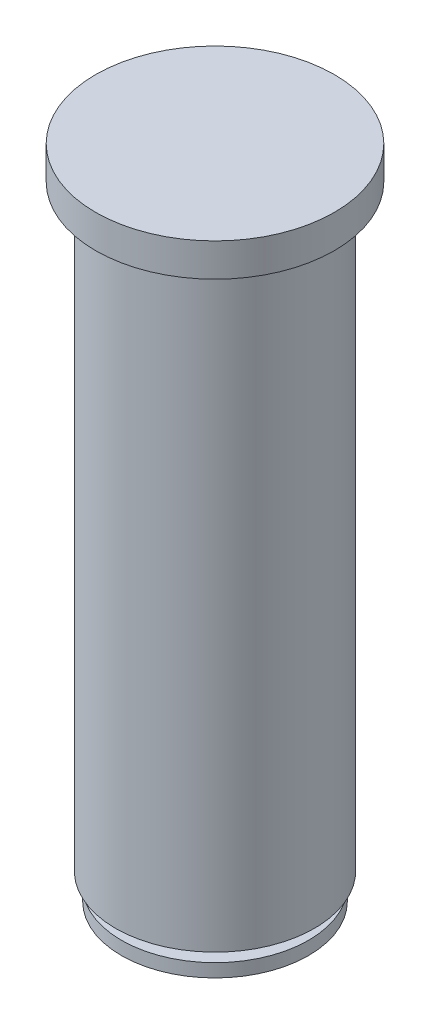
from build123d import *

# Parameters (mm, degrees)
SKETCH1_R           = 15
BOSS_EXTRUDE1_DEPTH = 90
SKETCH2_R           = 18
BOSS_EXTRUDE2_DEPTH = 5
SKETCH3_R           = 2.5
BOSS_EXTRUDE3_DEPTH = 2
SKETCH4_R           = 14.11079173
BOSS_EXTRUDE4_DEPTH = 2


with BuildPart() as part:
    # Sketch1 → Boss-Extrude1 (new body)
    with BuildSketch(Plane(origin=(0, 0, 0), x_dir=(1, 0, 0), z_dir=(0, 1, 0))):
        Circle(SKETCH1_R)
    extrude(amount=BOSS_EXTRUDE1_DEPTH)

    # Sketch2 → Boss-Extrude2 (add)
    with BuildSketch(Plane(origin=(0, 90, 0), x_dir=(1, 0, 0), z_dir=(0, 1, 0))):
        Circle(SKETCH2_R)
    extrude(amount=BOSS_EXTRUDE2_DEPTH)

    # Sketch3 → Boss-Extrude3 (add)
    with BuildSketch(Plane.XZ):
        Circle(SKETCH3_R)
    extrude(amount=BOSS_EXTRUDE3_DEPTH)

    # Sketch4 → Boss-Extrude4 (add)
    with BuildSketch(Plane.XZ.offset(2)):
        Circle(SKETCH4_R)
    extrude(amount=BOSS_EXTRUDE4_DEPTH)


solid = part.part
